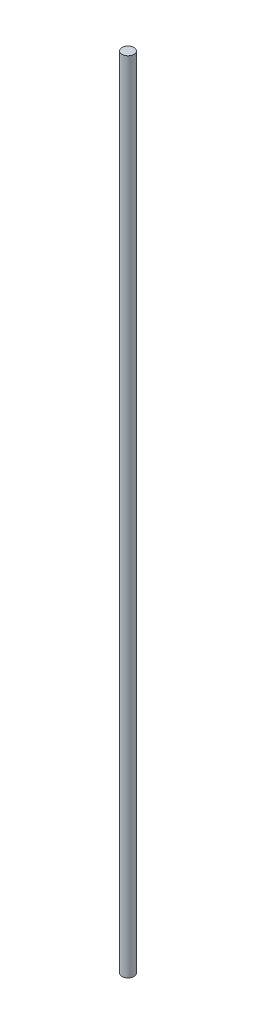
from build123d import *

# Parameters (mm, degrees)
SKETCH1_R           = 0.75
BOSS_EXTRUDE1_DEPTH = 100


with BuildPart() as part:
    # Sketch1 → Boss-Extrude1 (new body)
    with BuildSketch(Plane(origin=(0, 0, 0), x_dir=(1, 0, 0), z_dir=(0, 1, 0))):
        Circle(SKETCH1_R)
    extrude(amount=BOSS_EXTRUDE1_DEPTH)


solid = part.part
